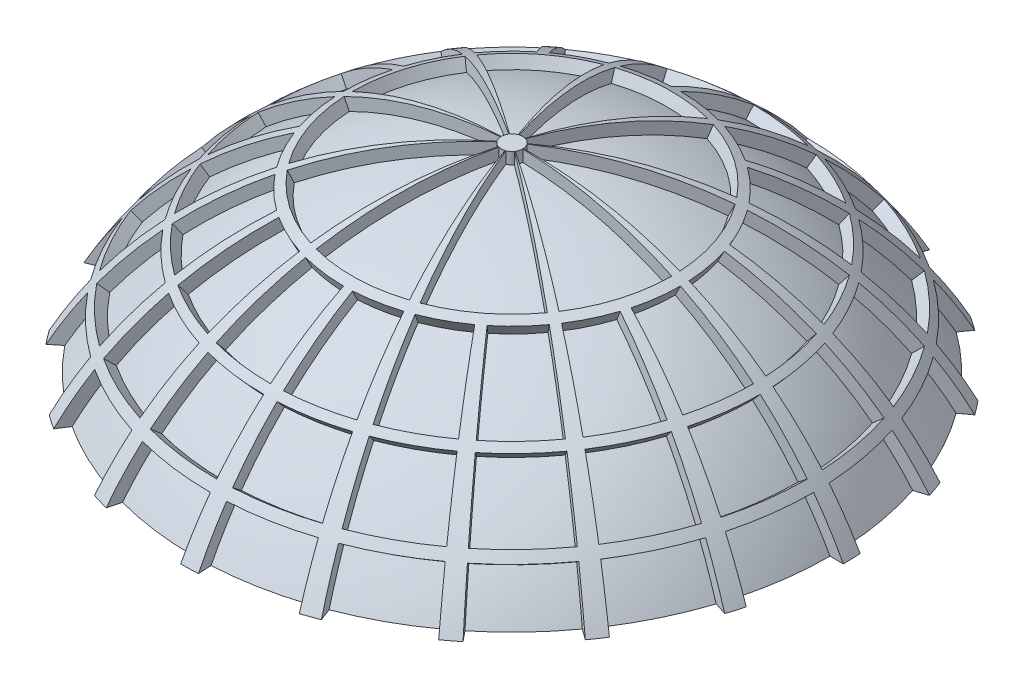
from build123d import *

# Parameters (mm, degrees)
REVOLVE_2_ANGLE          = 3
REVOLVE_3_ANGLE          = 3
PATTERN_CIRCULAR_3_COUNT = 20
PATTERN_CIRCULAR_4_COUNT = 10


with BuildPart() as part:
    # 草图1 → 旋转1 (revolve)
    with BuildSketch(Plane.XY):
        with BuildLine():
            Line((0, 310), (0, 300))
            ThreePointArc((0, 300), (150, 259.807621135), (259.807621135, 150))
            Line((259.807621135, 150), (271.293199325, 150))
            ThreePointArc((271.293199325, 150), (260.86202693, 167.484336301), (249.30566955, 184.246256761))
            ThreePointArc((249.30566955, 184.246256761), (246.702616609, 187.717391199), (244.051238042, 191.151754399))
            ThreePointArc((244.051238042, 191.151754399), (225.561573766, 212.654594214), (205.184234191, 232.377774409))
            ThreePointArc((205.184234191, 232.377774409), (202.413399752, 234.795263157), (199.614084683, 237.179714976))
            ThreePointArc((199.614084683, 237.179714976), (170.612647572, 258.826823356), (139.286048295, 276.946559376))
            ThreePointArc((139.286048295, 276.946559376), (135.698993593, 278.721694774), (132.089320414, 280.450372495))
            ThreePointArc((132.089320414, 280.450372495), (72.146553697, 301.487768889), (9.174001596, 309.864224613))
            ThreePointArc((9.174001596, 309.864224613), (4.58750314, 309.966054295), (0, 310))
        make_face()
        with BuildLine():
            Line((136.350266234, 289.497158705), (132.089320414, 280.450372495))
            ThreePointArc((132.089320414, 280.450372495), (135.698993593, 278.721694774), (139.286048295, 276.946559376))
            Line((139.286048295, 276.946559376), (143.779146627, 285.880319356))
            ThreePointArc((143.779146627, 285.880319356), (140.076380483, 287.712717186), (136.350266234, 289.497158705))
        make_face()
        with BuildLine():
            Line((206.053248705, 244.830673524), (199.614084683, 237.179714976))
            ThreePointArc((199.614084683, 237.179714976), (202.413399752, 234.795263157), (205.184234191, 232.377774409))
            Line((205.184234191, 232.377774409), (211.803080455, 239.873831648))
            ThreePointArc((211.803080455, 239.873831648), (208.94286426, 242.369303904), (206.053248705, 244.830673524))
        make_face()
        with BuildLine():
            ThreePointArc((244.051238042, 191.151754399), (246.702616609, 187.717391199), (249.30566955, 184.246256761))
            Line((249.30566955, 184.246256761), (257.347787922, 190.189684398))
            ThreePointArc((257.347787922, 190.189684398), (254.660765532, 193.772790915), (251.923858624, 197.317940025))
            Line((251.923858624, 197.317940025), (244.051238042, 191.151754399))
        make_face()
        with BuildLine():
            Line((0, 320), (0, 310))
            ThreePointArc((0, 310), (4.58750314, 309.966054295), (9.174001596, 309.864224613))
            Line((9.174001596, 309.864224613), (9.174001596, 319.868469366))
            ThreePointArc((9.174001596, 319.868469366), (4.587472223, 319.967115652), (0, 320))
        make_face()
    revolve(axis=Axis((0, 300, 0), (0, -1, 0)))

    # 草图1<3> → 旋转2 (revolve)
    with BuildSketch(Plane.XY):
        with BuildLine():
            Line((9.174001596, 319.868469366), (9.174001596, 309.864224613))
            ThreePointArc((9.174001596, 309.864224613), (72.146553697, 301.487768889), (132.089320414, 280.450372495))
            Line((132.089320414, 280.450372495), (136.350266234, 289.497158705))
            ThreePointArc((136.350266234, 289.497158705), (74.329888064, 311.24759877), (9.174001596, 319.868469366))
        make_face()
    revolve_2 = revolve(axis=Axis((0, 300, 0), (0, 1, 0)), revolution_arc=REVOLVE_2_ANGLE)

    # 草图1<5> → 旋转3 (revolve)
    with BuildSketch(Plane.XY):
        with BuildLine():
            ThreePointArc((249.30566955, 184.246256761), (260.86202693, 167.484336301), (271.293199325, 150))
            Line((271.293199325, 150), (282.665880502, 150))
            ThreePointArc((282.665880502, 150), (270.753565451, 170.565256708), (257.347787922, 190.189684398))
            Line((257.347787922, 190.189684398), (249.30566955, 184.246256761))
        make_face()
        with BuildLine():
            Line((143.779146627, 285.880319356), (139.286048295, 276.946559376))
            ThreePointArc((139.286048295, 276.946559376), (170.612647572, 258.826823356), (199.614084683, 237.179714976))
            Line((199.614084683, 237.179714976), (206.053248705, 244.830673524))
            ThreePointArc((206.053248705, 244.830673524), (176.116281365, 267.176075722), (143.779146627, 285.880319356))
        make_face()
        with BuildLine():
            ThreePointArc((205.184234191, 232.377774409), (225.561573766, 212.654594214), (244.051238042, 191.151754399))
            Line((244.051238042, 191.151754399), (251.923858624, 197.317940025))
            ThreePointArc((251.923858624, 197.317940025), (232.837753565, 219.514419834), (211.803080455, 239.873831648))
            Line((211.803080455, 239.873831648), (205.184234191, 232.377774409))
        make_face()
    revolve_3 = revolve(axis=Axis((0, 300, 0), (0, 1, 0)), revolution_arc=REVOLVE_3_ANGLE)

    # 阵列(圆周)3: 旋转3 ×20 about axis
    pattern_circular_3_axis = Axis((0, 0, 0), (0, 1, 0))
    for i in range(1, PATTERN_CIRCULAR_3_COUNT):
        add(revolve_3.rotate(pattern_circular_3_axis, i * 360 / PATTERN_CIRCULAR_3_COUNT))

    # 阵列(圆周)4: 旋转2 ×10 about axis
    pattern_circular_4_axis = Axis((0, 0, 0), (0, 1, 0))
    for i in range(1, PATTERN_CIRCULAR_4_COUNT):
        add(revolve_2.rotate(pattern_circular_4_axis, i * 360 / PATTERN_CIRCULAR_4_COUNT))


solid = part.part
